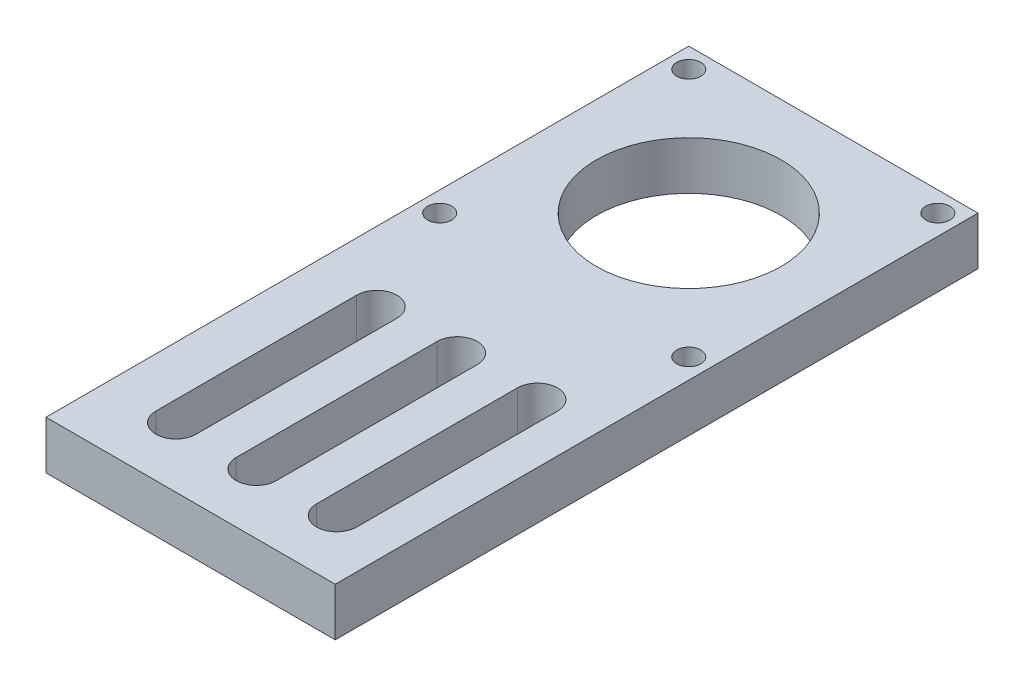
from build123d import *

# Parameters (mm, degrees)
SKETCH1_W           = 36
SKETCH1_H           = 80
SKETCH1_R           = 11.5
SKETCH1_R_2         = 1.5
BOSS_EXTRUDE1_DEPTH = 6


with BuildPart() as part:
    # Sketch1 → Boss-Extrude1 (new body)
    with BuildSketch(Plane(origin=(0, 0, 0), x_dir=(1, 0, 0), z_dir=(0, 1, 0))):
        Rectangle(SKETCH1_W, SKETCH1_H)
        with Locations((0, 22)):
            Circle(SKETCH1_R, mode=Mode.SUBTRACT)
        with Locations((-15.5, 37.5)):
            Circle(SKETCH1_R_2, mode=Mode.SUBTRACT)
        with Locations((15.5, 37.5)):
            Circle(SKETCH1_R_2, mode=Mode.SUBTRACT)
        with Locations((15.5, 6.5)):
            Circle(SKETCH1_R_2, mode=Mode.SUBTRACT)
        with Locations((-15.5, 6.5)):
            Circle(SKETCH1_R_2, mode=Mode.SUBTRACT)
        with BuildLine():
            Line((-1.827248673, -32.5), (-1.827248673, -7.5))
            ThreePointArc((-1.827248673, -7.5), (0.672751327, -5), (3.172751327, -7.5))
            Line((3.172751327, -7.5), (3.172751327, -32.5))
            ThreePointArc((3.172751327, -32.5), (0.672751327, -35), (-1.827248673, -32.5))
        make_face(mode=Mode.SUBTRACT)
        with BuildLine():
            Line((8.172751327, -32.5), (8.172751327, -7.5))
            ThreePointArc((8.172751327, -7.5), (10.672751327, -5), (13.172751327, -7.5))
            Line((13.172751327, -7.5), (13.172751327, -32.5))
            ThreePointArc((13.172751327, -32.5), (10.672751327, -35), (8.172751327, -32.5))
        make_face(mode=Mode.SUBTRACT)
        with BuildLine():
            Line((-6.827248673, -32.5), (-6.827248673, -7.5))
            ThreePointArc((-6.827248673, -7.5), (-9.327248673, -5), (-11.827248673, -7.5))
            Line((-11.827248673, -7.5), (-11.827248673, -32.5))
            ThreePointArc((-11.827248673, -32.5), (-9.327248673, -35), (-6.827248673, -32.5))
        make_face(mode=Mode.SUBTRACT)
    extrude(amount=BOSS_EXTRUDE1_DEPTH)


solid = part.part
